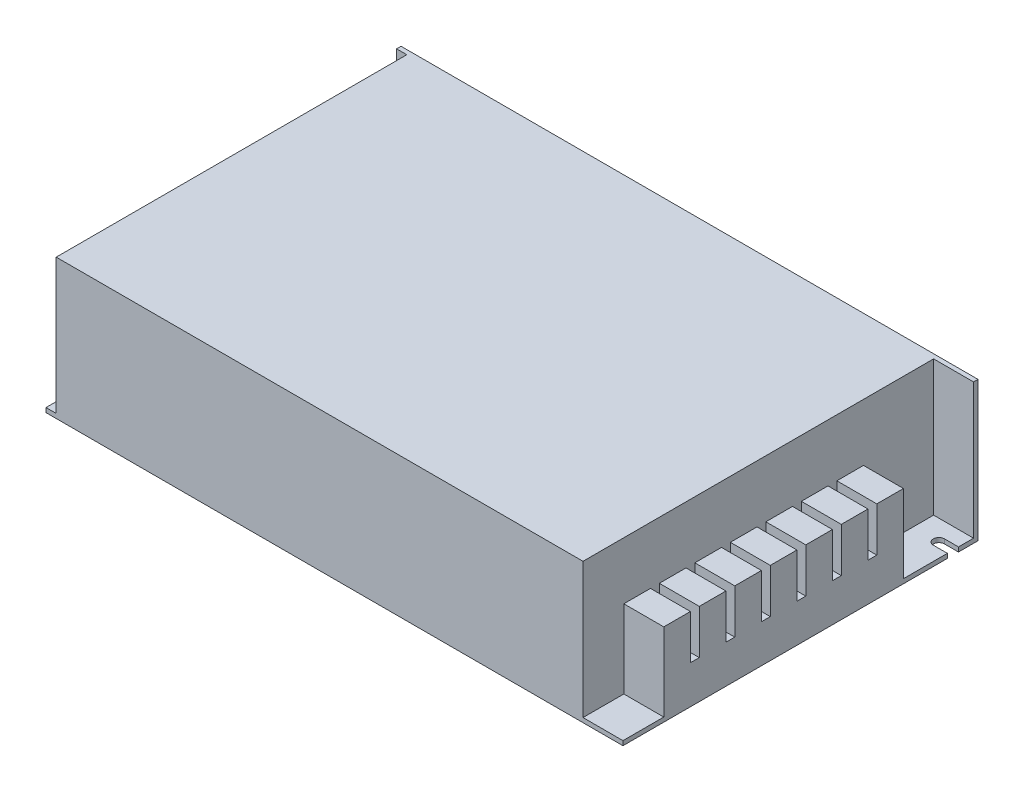
from build123d import *

# Parameters (mm, degrees)
SKETCH1_W           = 165.1
SKETCH1_H           = 101.6
BOSS_EXTRUDE1_DEPTH = 40
SKETCH2_W           = 100.33
SKETCH2_H           = 38.73
CUT_EXTRUDE1_DEPTH  = 11.43
SKETCH3_W           = 100.33
SKETCH3_H           = 38.73
CUT_EXTRUDE2_DEPTH  = 2.921
SKETCH4_W           = 11.43
SKETCH4_H           = 68.58
BOSS_EXTRUDE2_DEPTH = 22.352
CUT_EXTRUDE3_DEPTH  = 22.352
SKETCH6_R           = 1.27
CUT_EXTRUDE4_DEPTH  = 10.16
SKETCH7_W           = 11.43
SKETCH7_H           = 2.54
CUT_EXTRUDE5_DEPTH  = 12.7


with BuildPart() as part:
    # Sketch1 → Boss-Extrude1 (new body)
    with BuildSketch(Plane(origin=(0, 0, 0), x_dir=(1, 0, 0), z_dir=(0, 1, 0))):
        with Locations((82.55, 50.8)):
            Rectangle(SKETCH1_W, SKETCH1_H)
    extrude(amount=BOSS_EXTRUDE1_DEPTH)

    # Sketch2 → Cut-Extrude1 (cut)
    with BuildSketch(Plane(origin=(165.1, 0, 0), x_dir=(0, 0, -1), z_dir=(1, 0, 0))):
        with Locations((50.165, 20.635)):
            Rectangle(SKETCH2_W, SKETCH2_H)
    extrude(amount=-CUT_EXTRUDE1_DEPTH, mode=Mode.SUBTRACT)

    # Sketch3 → Cut-Extrude2 (cut)
    with BuildSketch(Plane.ZY):
        with Locations((-50.165, 20.635)):
            Rectangle(SKETCH3_W, SKETCH3_H)
    extrude(amount=-CUT_EXTRUDE2_DEPTH, mode=Mode.SUBTRACT)

    # Sketch4 → Boss-Extrude2 (add)
    with BuildSketch(Plane(origin=(0, 1.27, 0), x_dir=(1, 0, 0), z_dir=(0, 1, 0))):
        with Locations((159.385, 45.974)):
            Rectangle(SKETCH4_W, SKETCH4_H)
    extrude(amount=BOSS_EXTRUDE2_DEPTH)

    # Sketch5 → Cut-Extrude3 (cut)
    with BuildSketch(Plane(origin=(0, 1.27, 0), x_dir=(1, 0, 0), z_dir=(0, 1, 0))):
        with BuildLine():
            Line((0, 8.255), (0, 5.08))
            Line((0, 5.08), (4.0005, 5.08))
            ThreePointArc((4.0005, 5.08), (5.588, 6.6675), (4.0005, 8.255))
            Line((4.0005, 8.255), (0, 8.255))
        make_face()
        with BuildLine():
            Line((165.1, 92.837), (165.1, 96.012))
            Line((165.1, 96.012), (161.0995, 96.012))
            ThreePointArc((161.0995, 96.012), (159.512, 94.4245), (161.0995, 92.837))
            Line((161.0995, 92.837), (165.1, 92.837))
        make_face()
    extrude(amount=-CUT_EXTRUDE3_DEPTH, mode=Mode.SUBTRACT)

    # Sketch6 → Cut-Extrude4 (cut)
    with BuildSketch(Plane.XZ):
        with Locations((63.246, -65.278)):
            Circle(SKETCH6_R)
        with Locations((140.97, -65.278)):
            Circle(SKETCH6_R)
    extrude(amount=-CUT_EXTRUDE4_DEPTH, mode=Mode.SUBTRACT)

    # Sketch7 → Cut-Extrude5 (cut)
    with BuildSketch(Plane(origin=(0, 23.622, 0), x_dir=(1, 0, 0), z_dir=(0, 1, 0))):
        with Locations((159.385, 71.374)):
            Rectangle(SKETCH7_W, SKETCH7_H)
        with Locations((159.385, 61.214)):
            Rectangle(SKETCH7_W, SKETCH7_H)
        with Locations((159.385, 51.054)):
            Rectangle(SKETCH7_W, SKETCH7_H)
        with Locations((159.385, 40.894)):
            Rectangle(SKETCH7_W, SKETCH7_H)
        with Locations((159.385, 30.734)):
            Rectangle(SKETCH7_W, SKETCH7_H)
        with Locations((159.385, 20.574)):
            Rectangle(SKETCH7_W, SKETCH7_H)
    extrude(amount=-CUT_EXTRUDE5_DEPTH, mode=Mode.SUBTRACT)


solid = part.part
